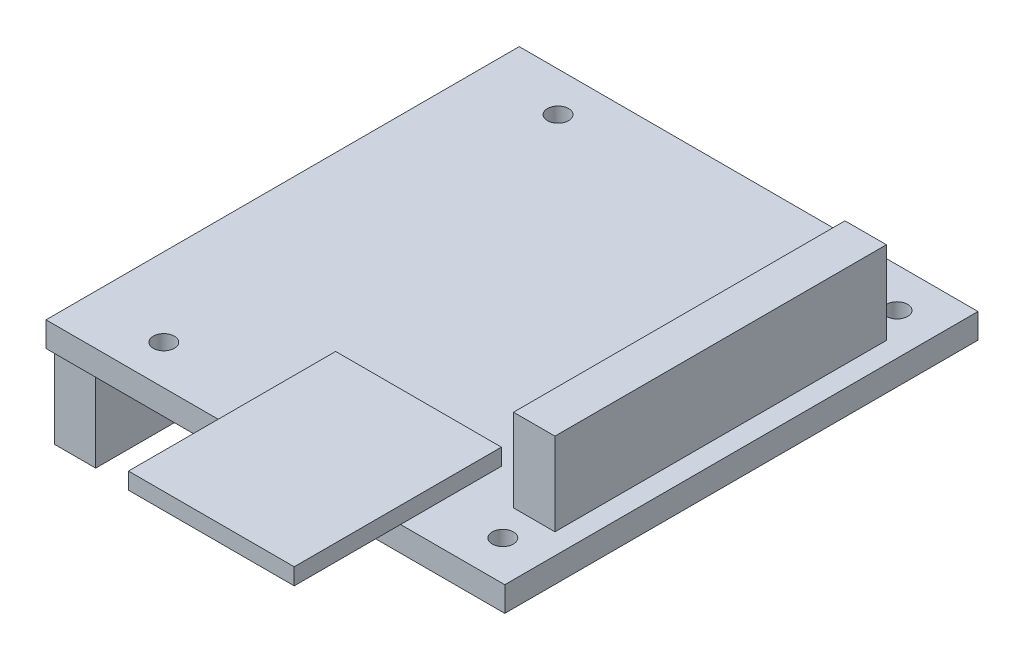
from build123d import *

# Parameters (mm, degrees)
ESQUISSE1_W      = 55.36
ESQUISSE1_H      = 57.1
ESQUISSE1_R      = 1.275
EXTRUSION1_DEPTH = 3
ESQUISSE2_W      = 5
ESQUISSE2_H      = 40
EXTRUSION2_DEPTH = 10
ESQUISSE3_W      = 20
ESQUISSE3_H      = 25
EXTRUSION3_DEPTH = 2
ESQUISSE4_W      = 5
ESQUISSE4_H      = 56.1
EXTRUSION4_DEPTH = 10
ESQUISSE5_W      = 10
ESQUISSE5_H      = 5
EXTRUSION5_DEPTH = 5


with BuildPart() as part:
    # Esquisse1 → Extrusion1 (new body)
    with BuildSketch(Plane(origin=(0, 0, 0), x_dir=(1, 0, 0), z_dir=(0, 1, 0))):
        with Locations((27.68, 28.55)):
            Rectangle(ESQUISSE1_W, ESQUISSE1_H)
        with Locations((9.45, 52.335)):
            Circle(ESQUISSE1_R, mode=Mode.SUBTRACT)
        with Locations((50.36, 52.335)):
            Circle(ESQUISSE1_R, mode=Mode.SUBTRACT)
        with Locations((9.45, 4.765)):
            Circle(ESQUISSE1_R, mode=Mode.SUBTRACT)
        with Locations((50.36, 4.765)):
            Circle(ESQUISSE1_R, mode=Mode.SUBTRACT)
    extrude(amount=EXTRUSION1_DEPTH)

    # Esquisse2 → Extrusion2 (add)
    with BuildSketch(Plane(origin=(0, 3, 0), x_dir=(1, 0, 0), z_dir=(0, 1, 0))):
        with Locations((50.36, 28.55)):
            Rectangle(ESQUISSE2_W, ESQUISSE2_H)
    extrude(amount=EXTRUSION2_DEPTH)

    # Esquisse3 → Extrusion3 (add)
    with BuildSketch(Plane(origin=(0, 3, 0), x_dir=(1, 0, 0), z_dir=(0, 1, 0))):
        with Locations((32.78027682, -0.33040493)):
            Rectangle(ESQUISSE3_W, ESQUISSE3_H)
    extrude(amount=EXTRUSION3_DEPTH)

    # Esquisse4 → Extrusion4 (add)
    with BuildSketch(Plane.XZ):
        with Locations((3, -28.55)):
            Rectangle(ESQUISSE4_W, ESQUISSE4_H)
    extrude(amount=EXTRUSION4_DEPTH)

    # Esquisse5 → Extrusion5 (add)
    with BuildSketch(Plane.XZ):
        with Locations((17.244150354, -57.432970226)):
            Rectangle(ESQUISSE5_W, ESQUISSE5_H)
    extrude(amount=EXTRUSION5_DEPTH)


solid = part.part
